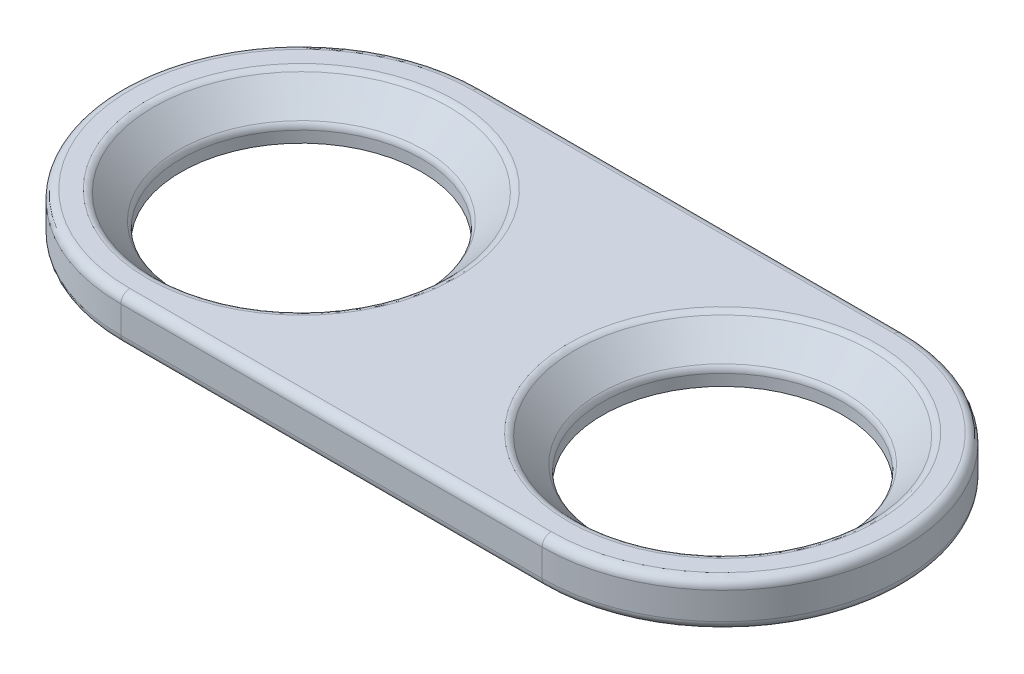
from build123d import *

# Parameters (mm, degrees)
BOSS_EXTRUDE1_DEPTH = 1.5
SKETCH2_R           = 4
CUT_EXTRUDE2_DEPTH  = 2.5
CHAMFER1_SIZE       = 1
FILLET1_R           = 0.3


with BuildPart() as part:
    # Sketch1 → Boss-Extrude1 (new body)
    with BuildSketch(Plane(origin=(0, 0, 0), x_dir=(1, 0, 0), z_dir=(0, 1, 0))):
        with BuildLine():
            Line((-7, 6), (7, 6))
            ThreePointArc((7, 6), (13, 0), (7, -6))
            Line((7, -6), (-7, -6))
            ThreePointArc((-7, -6), (-13, 0), (-7, 6))
        make_face()
    extrude(amount=BOSS_EXTRUDE1_DEPTH)

    # Sketch2 → Cut-Extrude2 (cut, through all)
    with BuildSketch(Plane(origin=(0, 0, 0), x_dir=(1, 0, 0), z_dir=(0, 1, 0))):
        with Locations(Location((-7, 0, 0), (0, 0, 270))):  # turned: the seam where the file's is
            Circle(SKETCH2_R)
        with Locations(Location((7, 0, 0), (0, 0, 270))):  # turned: the seam where the file's is
            Circle(SKETCH2_R)
    extrude(amount=CUT_EXTRUDE2_DEPTH, mode=Mode.SUBTRACT)

    # Chamfer1
    chamfer1_edges = [part.edges().sort_by_distance(p)[0] for p in [
        (-7, 1.5, -4),
        (7, 1.5, -4),
    ]]
    chamfer(chamfer1_edges, length=CHAMFER1_SIZE)

    # Fillet1
    fillet1_edges = [part.edges().sort_by_distance(p)[0] for p in [
        (13, 1.5, 0),
        (0, 1.5, -6),
        (-7, 0.5, -4),
        (7, 1.5, -5),
        (-7, 1.5, -5),
        (7, 0.5, -4),
        (-13, 1.5, 0),
        (0, 0, -6),
        (13, 0, 0),
        (0, 0, 6),
        (-13, 0, 0),
        (0, 1.5, 6),
    ]]
    fillet(fillet1_edges, radius=FILLET1_R)


solid = part.part
